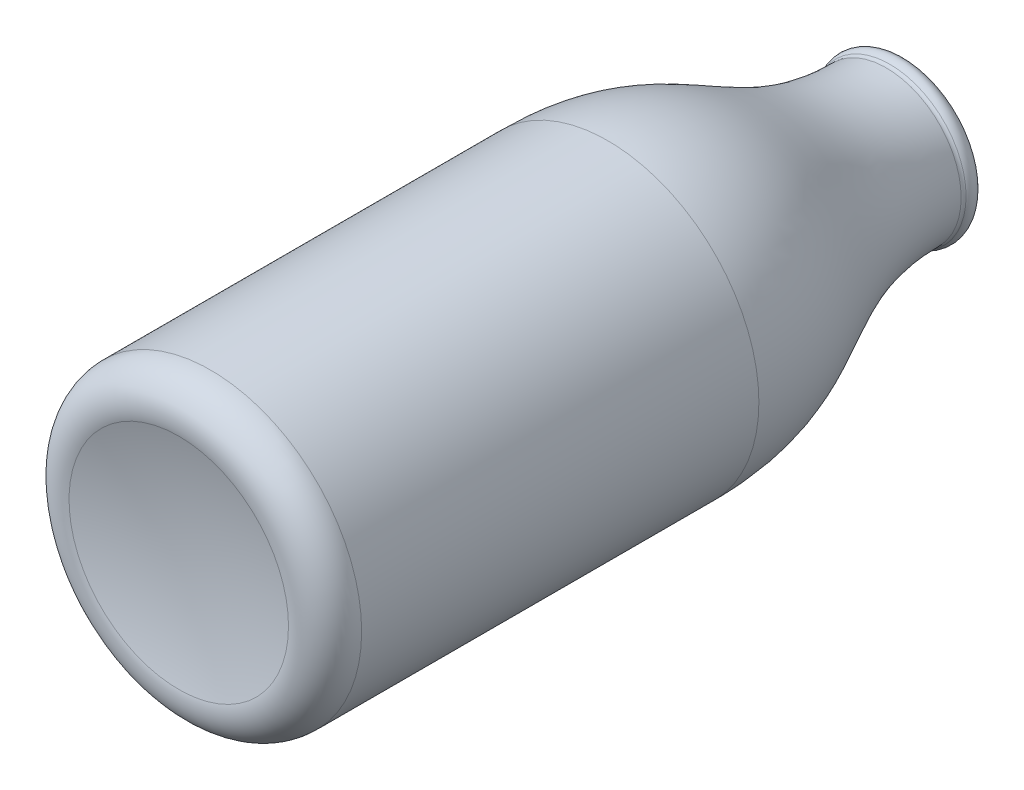
from build123d import *


with BuildPart() as part:
    # Skizze1 → Rotation1 (revolve)
    with BuildSketch(Plane(origin=(0, 0, 0), x_dir=(0, 0, -1), z_dir=(1, 0, 0)), mode=Mode.PRIVATE) as rotation1_sk:
        with BuildLine():
            Line((6.43310772, 26.502092491), (78.775337829, 26.502092491))
            add(Edge.make_bspline(
                [(78.775337829, 26.502092491), (85.768114648, 26.502092491), (97.22355657, 24.436963779), (112.76171299, 14.68984773), (123.561518894, 12.639961843), (129.472123395, 12.639961843)],
                knots=[0, 0, 0, 0, 0.356699684, 0.679310779, 0.987664655, 0.987664655, 0.987664655, 0.987664655], degree=3))
            Line((129.472123395, 12.639961843), (132.246854305, 12.636540919))
            ThreePointArc((132.246854305, 12.636540919), (132.670763891, 12.87041479), (132.697800048, 13.353804252))
            ThreePointArc((132.697800048, 13.353804252), (131.543535807, 14.254094557), (130.127151947, 13.884357717))
            ThreePointArc((130.127151947, 13.884357717), (129.82169161, 13.703050928), (129.472123395, 13.639961843))
            add(Edge.make_bspline(
                [(78.775337829, 27.502092491), (79.382538376, 27.502092491), (80.606402074, 27.485616936), (82.977070827, 27.385543253), (85.857643305, 27.132509268), (89.187544589, 26.61641907), (93.490625176, 25.639672892), (98.680772531, 23.83922281), (104.687501054, 20.828271238), (110.596687704, 17.745265037), (115.535803916, 15.750615975), (119.621935707, 14.660048856), (122.775284135, 14.071640762), (125.500071284, 13.777596815), (127.741487977, 13.659645547), (128.898157401, 13.639961843), (129.472123395, 13.639961843)],
                knots=[0, 0, 0, 0, 0.03086452, 0.061729041, 0.123458082, 0.185187123, 0.246916164, 0.370374246, 0.493832328, 0.617290409, 0.740748491, 0.802477532, 0.864206573, 0.925935614, 0.956800135, 0.987664655, 0.987664655, 0.987664655, 0.987664655], degree=3))
            Line((78.775337829, 27.502092491), (6.43310772, 27.502092491))
            ThreePointArc((6.43310772, 27.502092491), (1.683858471, 25.168784674), (0.628429354, 19.983636346))
            ThreePointArc((0.628429354, 19.983636346), (2.553690069, 10.07414195), (3.198958976, 0))
            Line((3.198958976, 0), (4.198958976, 0))
            ThreePointArc((4.198958976, 0), (3.545518279, 10.201722524), (1.595875749, 20.23671237))
            ThreePointArc((1.595875749, 20.23671237), (2.475400012, 24.55766931), (6.43310772, 26.502092491))
        make_face()
    revolve(rotation1_sk.sketch.rotate(Axis((0, 0, 0), (0, 0, -1)), 90), axis=Axis((0, 0, 0), (0, 0, -1)))  # turned: the seam where the file's is


solid = part.part
